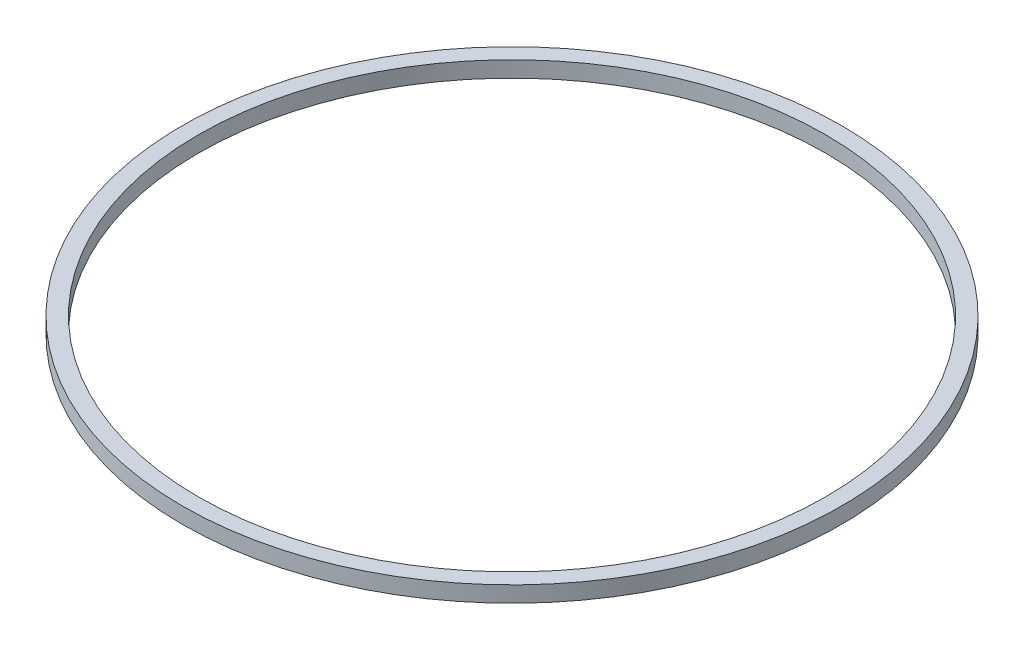
from build123d import *

# Parameters (mm, degrees)
SKETCH1_W = 76.2
SKETCH1_H = 76.2


with BuildPart() as part:
    # Sketch1 → Revolve1 (revolve)
    with BuildSketch(Plane.XY):
        with Locations((1538.1, -12.964583333)):
            Rectangle(SKETCH1_W, SKETCH1_H)
    revolve(axis=Axis((0, 0, 0), (0, 1, 0)))


solid = part.part
